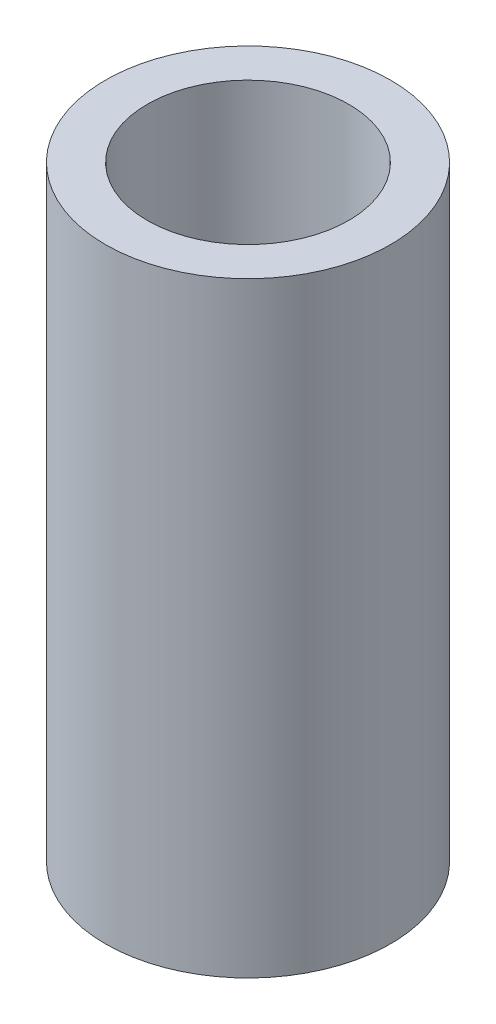
from build123d import *

# Parameters (mm, degrees)
SKETCH1_R           = 9.525
SKETCH1_R_2         = 6.731
BOSS_EXTRUDE1_DEPTH = 40.470836


with BuildPart() as part:
    # Sketch1 → Boss-Extrude1 (new body)
    with BuildSketch(Plane(origin=(0, 0, 0), x_dir=(1, 0, 0), z_dir=(0, 1, 0))):
        Circle(SKETCH1_R)
        Circle(SKETCH1_R_2, mode=Mode.SUBTRACT)
    extrude(amount=BOSS_EXTRUDE1_DEPTH)


solid = part.part
